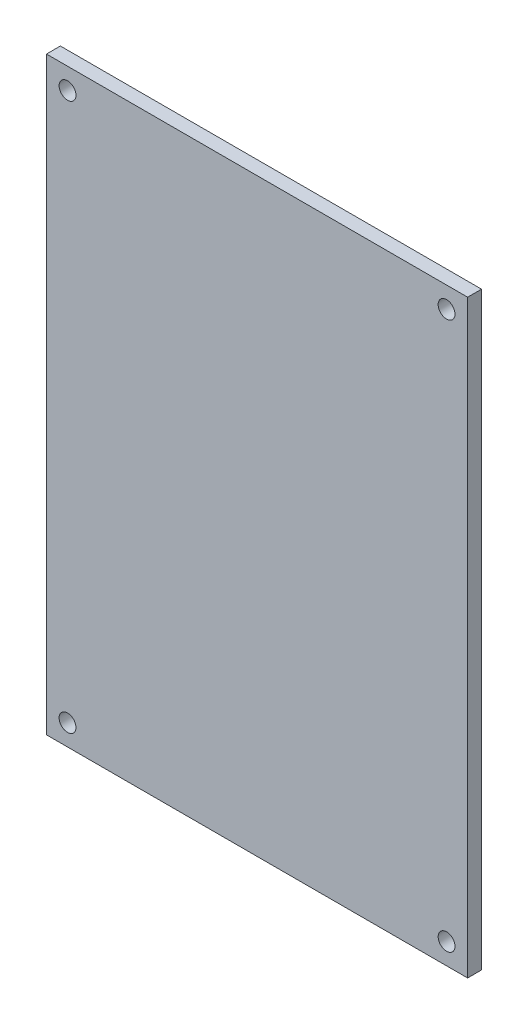
from build123d import *

# Parameters (mm, degrees)
SKETCH_1_W      = 50
SKETCH_1_H      = 70
SKETCH_1_R      = 1
EXTRUDE_1_DEPTH = 1.65


with BuildPart() as part:
    # 草图1 → 凸台-拉伸1 (new body)
    with BuildSketch(Plane.XY):
        Rectangle(SKETCH_1_W, SKETCH_1_H)
        with Locations((-22.5, 32.5)):
            Circle(SKETCH_1_R, mode=Mode.SUBTRACT)
        with Locations((22.5, 32.5)):
            Circle(SKETCH_1_R, mode=Mode.SUBTRACT)
        with Locations((22.5, -32.5)):
            Circle(SKETCH_1_R, mode=Mode.SUBTRACT)
        with Locations((-22.5, -32.5)):
            Circle(SKETCH_1_R, mode=Mode.SUBTRACT)
    extrude(amount=EXTRUDE_1_DEPTH)


solid = part.part
